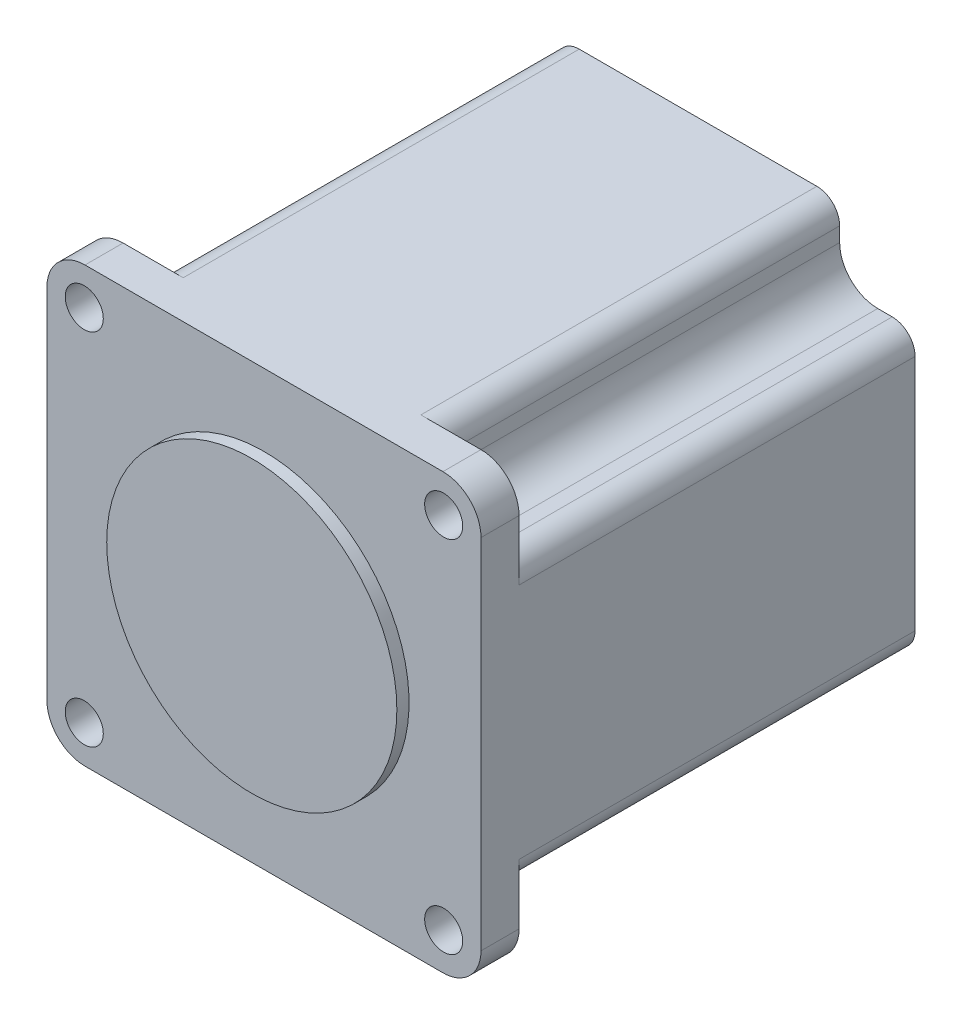
from build123d import *

# Parameters (mm, degrees)
BOSS_EXTRUDE1_DEPTH = 2.5
SKETCH5_R           = 2.5
CUT_EXTRUDE1_DEPTH  = 6
SKETCH3_R           = 19.05
BOSS_EXTRUDE3_DEPTH = 1.6
BODY_DEPTH          = 52


with BuildPart() as part:
    # Sketch1 → Boss-Extrude1 (new body, symmetric)
    with BuildSketch(Plane.XY):
        with BuildLine():
            Line((-23.5, -28.5), (23.5, -28.5))
            ThreePointArc((23.5, -28.5), (27.035533906, -27.035533906), (28.5, -23.5))
            Line((28.5, -23.5), (28.5, 23.5))
            ThreePointArc((28.5, 23.5), (27.035533906, 27.035533906), (23.5, 28.5))
            Line((23.5, 28.5), (-23.5, 28.5))
            ThreePointArc((-23.5, 28.5), (-27.035533906, 27.035533906), (-28.5, 23.5))
            Line((-28.5, 23.5), (-28.5, -23.5))
            ThreePointArc((-28.5, -23.5), (-27.035533906, -27.035533906), (-23.5, -28.5))
        make_face()
    extrude(amount=BOSS_EXTRUDE1_DEPTH, both=True)

    # Sketch5 → Cut-Extrude1 (cut, through all)
    with BuildSketch(Plane.XY.offset(2.5)):
        with Locations((-23.6, 23.6)):
            Circle(SKETCH5_R)
        with Locations((23.6, 23.6)):
            Circle(SKETCH5_R)
        with Locations((23.6, -23.6)):
            Circle(SKETCH5_R)
        with Locations((-23.6, -23.6)):
            Circle(SKETCH5_R)
    extrude(amount=-CUT_EXTRUDE1_DEPTH, mode=Mode.SUBTRACT)

    # Sketch3 → Boss-Extrude3 (add)
    with BuildSketch(Plane.XY.offset(2.5)):
        Circle(SKETCH3_R)
    extrude(amount=BOSS_EXTRUDE3_DEPTH)

    # Sketch4 → Body (add)
    with BuildSketch(Plane(origin=(0, 0, -2.5), x_dir=(-1, 0, 0), z_dir=(0, 0, -1))):
        with BuildLine():
            Line((-18.6, 23.6), (-18.6, 25.5))
            ThreePointArc((-18.6, 25.5), (-17.721320344, 27.621320344), (-15.6, 28.5))
            Line((-15.6, 28.5), (15.6, 28.5))
            ThreePointArc((15.6, 28.5), (17.721320344, 27.621320344), (18.6, 25.5))
            Line((18.6, 25.5), (18.6, 23.6))
            ThreePointArc((18.6, 23.6), (20.064466094, 20.064466094), (23.6, 18.6))
            Line((23.6, 18.6), (25.5, 18.6))
            ThreePointArc((25.5, 18.6), (27.621320344, 17.721320344), (28.5, 15.6))
            Line((28.5, 15.6), (28.5, -15.6))
            ThreePointArc((28.5, -15.6), (27.621320344, -17.721320344), (25.5, -18.6))
            Line((25.5, -18.6), (23.6, -18.6))
            ThreePointArc((23.6, -18.6), (20.064466094, -20.064466094), (18.6, -23.6))
            Line((18.6, -23.6), (18.6, -25.5))
            ThreePointArc((18.6, -25.5), (17.721320344, -27.621320344), (15.6, -28.5))
            Line((15.6, -28.5), (-15.6, -28.5))
            ThreePointArc((-15.6, -28.5), (-17.721320344, -27.621320344), (-18.6, -25.5))
            Line((-18.6, -25.5), (-18.6, -23.6))
            ThreePointArc((-18.6, -23.6), (-20.064466094, -20.064466094), (-23.6, -18.6))
            Line((-23.6, -18.6), (-25.5, -18.6))
            ThreePointArc((-25.5, -18.6), (-27.621320344, -17.721320344), (-28.5, -15.6))
            Line((-28.5, -15.6), (-28.5, 15.6))
            ThreePointArc((-28.5, 15.6), (-27.621320344, 17.721320344), (-25.5, 18.6))
            Line((-25.5, 18.6), (-23.6, 18.6))
            ThreePointArc((-23.6, 18.6), (-20.064466094, 20.064466094), (-18.6, 23.6))
        make_face()
    extrude(amount=BODY_DEPTH)


solid = part.part
